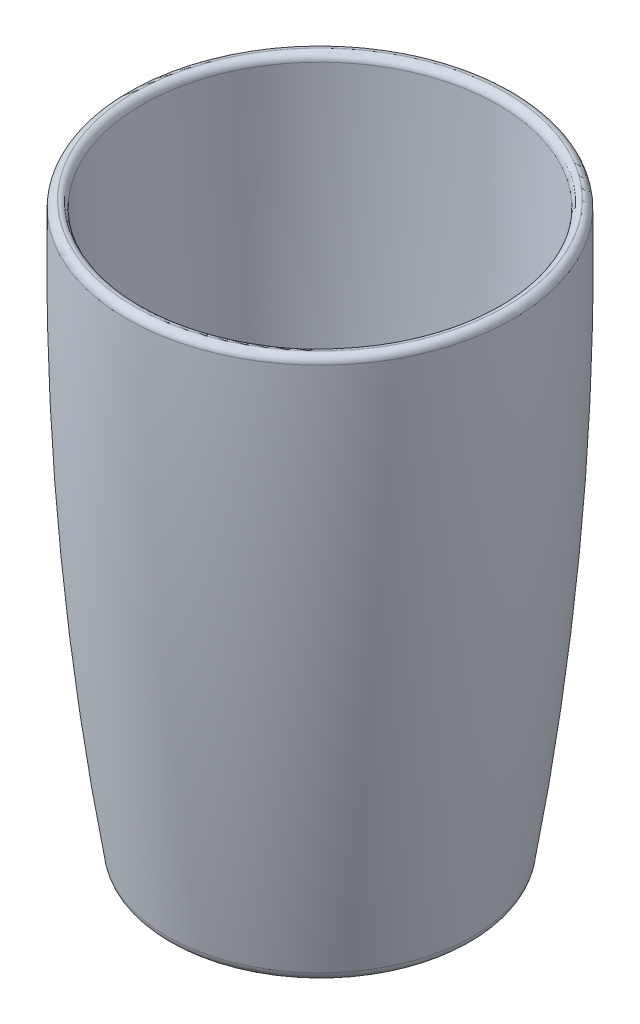
from build123d import *

# Parameters (mm, degrees)
FILLET2_R = 2.54
FILLET8_R = 1.524


with BuildPart() as part:
    # Sketch1 → Revolve2 (revolve)
    with BuildSketch(Plane.XY):
        with BuildLine():
            Line((-103.194631519, -2.149015704), (-71.3491365, -2.149015704))
            ThreePointArc((-71.3491365, -2.149015704), (-64.291015821, 57.937862835), (-62.554631519, 118.412940425))
            Line((-62.554631519, 118.412940425), (-65.602631519, 118.412940425))
            add(Edge.make_bspline(
                [(-97.147884871, 1.025984296), (-93.620112449, 1.032138915), (-90.092340027, 1.038293534), (-86.564567606, 1.044448135), (-83.036795184, 1.050602687), (-79.509022762, 1.056757138), (-75.981250339, 1.062911415), (-72.453477917, 1.069065413), (-68.925705493, 1.075218987), (-65.602631519, 118.412940425)],
                knots=[0.089900375, 0.089900375, 0.089900375, 0.089900375, 0.089900375, 0.089900375, 0.089900375, 0.089900375, 0.089900375, 0.089900375, 0.988904133, 0.988904133, 0.988904133, 0.988904133, 0.988904133, 0.988904133, 0.988904133, 0.988904133, 0.988904133, 0.988904133], degree=9))
            Line((-97.147884871, 1.025984296), (-103.194631519, 1.025984296))
            Line((-103.194631519, 1.025984296), (-103.194631519, -2.149015704))
        make_face()
    revolve(axis=Axis((-103.194631519, -2.149015704, 0), (0, 1, 0)))

    # Fillet2
    fillet2_edges = [part.edges().sort_by_distance(p)[0] for p in [
        (-135.040126539, -2.149015704, 0),
    ]]
    fillet(fillet2_edges, radius=FILLET2_R)

    # Fillet8
    fillet8_edges = [part.edges().sort_by_distance(p)[0] for p in [
        (-140.786631519, 118.412940425, 0),
        (-143.834631519, 118.412940425, 0),
    ]]
    fillet(fillet8_edges, radius=FILLET8_R)


solid = part.part
